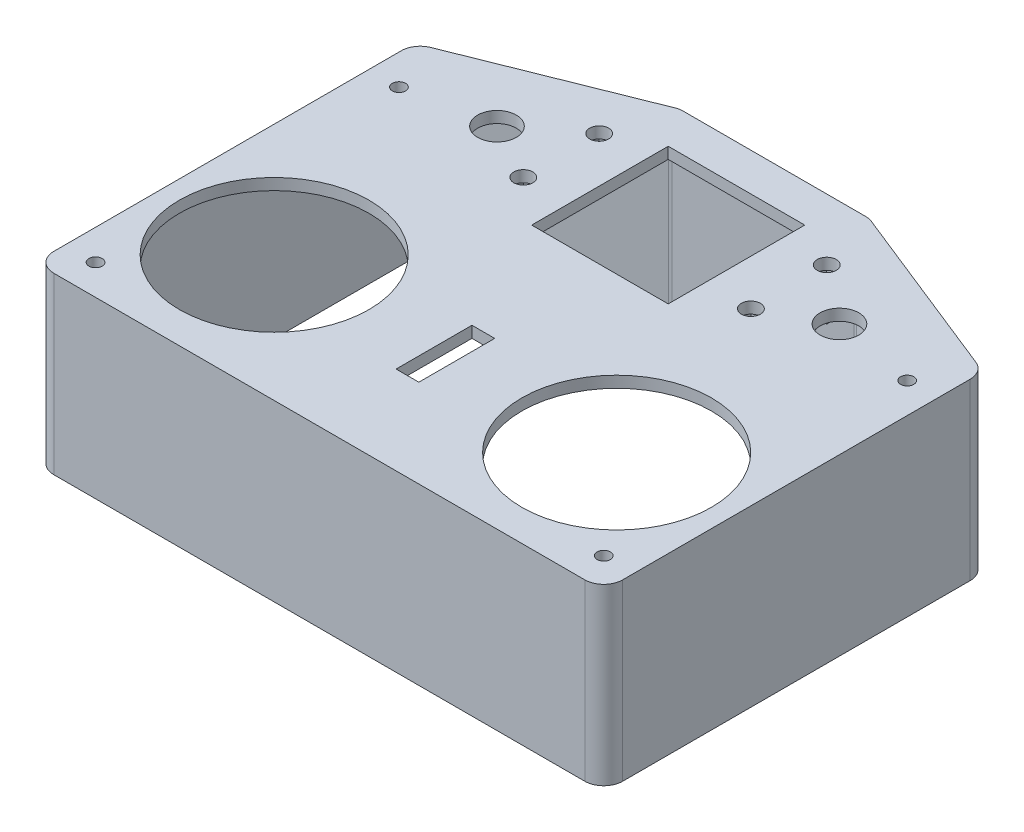
from build123d import *

# Parameters (mm, degrees)
SKETCH1_R           = 25
SKETCH1_R_2         = 5.1
SKETCH1_R_3         = 2.5
SKETCH1_W           = 36
SKETCH1_H           = 36
SKETCH1_W_2         = 6
SKETCH1_H_2         = 20
BOSS_EXTRUDE1_DEPTH = 3
BOSS_EXTRUDE2_DEPTH = 43
SKETCH4_W           = 11
SKETCH4_H           = 11
SKETCH4_W_2         = 7
SKETCH4_H_2         = 7
BOSS_EXTRUDE3_DEPTH = 5
SKETCH5_R           = 1.75
CUT_EXTRUDE1_DEPTH  = 5
SKETCH6_R           = 3.5
CUT_EXTRUDE2_DEPTH  = 3


with BuildPart() as part:
    # Sketch1 → Boss-Extrude1 (new body)
    with BuildSketch(Plane(origin=(0, 0, 0), x_dir=(1, 0, 0), z_dir=(0, 1, 0))):
        with BuildLine():
            Line((-20.833630945, -24.478740106), (119.166369055, -24.478740106))
            ThreePointArc((119.166369055, -24.478740106), (122.701902961, -23.014274012), (124.166369055, -19.478740106))
            Line((124.166369055, -19.478740106), (124.166369055, 72.136095087))
            ThreePointArc((124.166369055, 72.136095087), (123.306705208, 74.939239133), (121.023322437, 76.778478541))
            Line((121.023322437, 76.778478541), (75.060410419, 95.163643348))
            ThreePointArc((75.060410419, 95.163643348), (74.148994643, 95.431041828), (73.203457037, 95.521259894))
            Line((73.203457037, 95.521259894), (25.129281073, 95.521259894))
            ThreePointArc((25.129281073, 95.521259894), (24.183743467, 95.431041828), (23.272327691, 95.163643348))
            Line((23.272327691, 95.163643348), (-22.690584327, 76.778478541))
            ThreePointArc((-22.690584327, 76.778478541), (-24.973967097, 74.939239133), (-25.833630945, 72.136095087))
            Line((-25.833630945, 72.136095087), (-25.833630945, -19.478740106))
            ThreePointArc((-25.833630945, -19.478740106), (-24.369164851, -23.014274012), (-20.833630945, -24.478740106))
        make_face()
        with Locations((4.016369055, 8.771259894)):
            Circle(SKETCH1_R, mode=Mode.SUBTRACT)
        with Locations((94.316369055, 8.771259894)):
            Circle(SKETCH1_R, mode=Mode.SUBTRACT)
        with Locations((4.016369055, 67.521259894)):
            Circle(SKETCH1_R_2, mode=Mode.SUBTRACT)
        with Locations((94.316369055, 67.521259894)):
            Circle(SKETCH1_R_2, mode=Mode.SUBTRACT)
        with Locations((19.166369055, 79.316074422)):
            Circle(SKETCH1_R_3, mode=Mode.SUBTRACT)
        with Locations((19.166369055, 59.316074422)):
            Circle(SKETCH1_R_3, mode=Mode.SUBTRACT)
        with Locations((79.166369055, 59.316074422)):
            Circle(SKETCH1_R_3, mode=Mode.SUBTRACT)
        with Locations((79.166369055, 79.316074422)):
            Circle(SKETCH1_R_3, mode=Mode.SUBTRACT)
        with Locations((49.166369055, 67.521259894)):
            Rectangle(SKETCH1_W, SKETCH1_H, mode=Mode.SUBTRACT)
        with Locations((49.166369055, 8.771259894)):
            Rectangle(SKETCH1_W_2, SKETCH1_H_2, mode=Mode.SUBTRACT)
    extrude(amount=BOSS_EXTRUDE1_DEPTH)

    # Sketch2 → Boss-Extrude2 (add)
    with BuildSketch(Plane.XZ):
        with BuildLine():
            Line((-25.833630945, 19.478740106), (-25.833630945, -72.136095087))
            ThreePointArc((-25.833630945, -72.136095087), (-24.973967097, -74.939239133), (-22.690584327, -76.778478541))
            Line((-22.690584327, -76.778478541), (23.272327691, -95.163643348))
            ThreePointArc((23.272327691, -95.163643348), (24.183743467, -95.431041828), (25.129281073, -95.521259894))
            Line((25.129281073, -95.521259894), (73.203457037, -95.521259894))
            ThreePointArc((73.203457037, -95.521259894), (74.148994643, -95.431041828), (75.060410419, -95.163643348))
            Line((75.060410419, -95.163643348), (121.023322437, -76.778478541))
            ThreePointArc((121.023322437, -76.778478541), (123.306705208, -74.939239133), (124.166369055, -72.136095087))
            Line((124.166369055, -72.136095087), (124.166369055, 19.478740106))
            ThreePointArc((124.166369055, 19.478740106), (122.701902961, 23.014274012), (119.166369055, 24.478740106))
            Line((119.166369055, 24.478740106), (-20.833630945, 24.478740106))
            ThreePointArc((-20.833630945, 24.478740106), (-24.369164851, 23.014274012), (-25.833630945, 19.478740106))
        make_face()
        with BuildLine():
            Line((119.166369055, 21.478740106), (-20.833630945, 21.478740106))
            ThreePointArc((-20.833630945, 21.478740106), (-22.247844507, 20.892953668), (-22.833630945, 19.478740106))
            Line((-22.833630945, 19.478740106), (-22.833630945, -72.136095087))
            ThreePointArc((-22.833630945, -72.136095087), (-22.489765406, -73.257352705), (-21.576412297, -73.993048469))
            Line((-21.576412297, -73.993048469), (24.38649972, -92.378213276))
            ThreePointArc((24.38649972, -92.378213276), (24.751066031, -92.485172667), (25.129281073, -92.521259894))
            Line((25.129281073, -92.521259894), (73.203457037, -92.521259894))
            ThreePointArc((73.203457037, -92.521259894), (73.58167208, -92.485172667), (73.94623839, -92.378213276))
            Line((73.94623839, -92.378213276), (119.909150408, -73.993048469))
            ThreePointArc((119.909150408, -73.993048469), (120.822503516, -73.257352705), (121.166369055, -72.136095087))
            Line((121.166369055, -72.136095087), (121.166369055, 19.478740106))
            ThreePointArc((121.166369055, 19.478740106), (120.580582618, 20.892953668), (119.166369055, 21.478740106))
        make_face(mode=Mode.SUBTRACT)
    extrude(amount=BOSS_EXTRUDE2_DEPTH)

    # Sketch4 → Boss-Extrude3 (add)
    with BuildSketch(Plane.XZ):
        with Locations((79.166369055, -79.316074422)):
            Rectangle(SKETCH4_W, SKETCH4_H)
        with Locations((79.166369055, -79.316074422)):
            Rectangle(SKETCH4_W_2, SKETCH4_H_2, mode=Mode.SUBTRACT)
        with Locations((79.166369055, -59.316074422)):
            Rectangle(SKETCH4_W, SKETCH4_H)
        with Locations((79.166369055, -59.316074422)):
            Rectangle(SKETCH4_W_2, SKETCH4_H_2, mode=Mode.SUBTRACT)
        with Locations((19.166369055, -59.316074422)):
            Rectangle(SKETCH4_W, SKETCH4_H)
        with Locations((19.166369055, -59.316074422)):
            Rectangle(SKETCH4_W_2, SKETCH4_H_2, mode=Mode.SUBTRACT)
        with Locations((19.166369055, -79.316074422)):
            Rectangle(SKETCH4_W, SKETCH4_H)
        with Locations((19.166369055, -79.316074422)):
            Rectangle(SKETCH4_W_2, SKETCH4_H_2, mode=Mode.SUBTRACT)
    extrude(amount=BOSS_EXTRUDE3_DEPTH)

    # Sketch5 → Cut-Extrude1 (cut)
    with BuildSketch(Plane.XZ):
        with Locations((-17.833630945, 16.478740106)):
            Circle(SKETCH5_R)
        with Locations((116.166369055, 16.478740106)):
            Circle(SKETCH5_R)
        with Locations((-17.833630945, -63.521259894)):
            Circle(SKETCH5_R)
        with Locations((116.166369055, -63.521259894)):
            Circle(SKETCH5_R)
    extrude(amount=-CUT_EXTRUDE1_DEPTH, mode=Mode.SUBTRACT)

    # Sketch6 → Cut-Extrude2 (cut)
    with BuildSketch(Plane(origin=(0, 0, -95.521259894), x_dir=(-1, 0, 0), z_dir=(0, 0, -1))):
        with Locations((-49.166369055, -29.5)):
            Circle(SKETCH6_R)
    extrude(amount=-CUT_EXTRUDE2_DEPTH, mode=Mode.SUBTRACT)


solid = part.part
